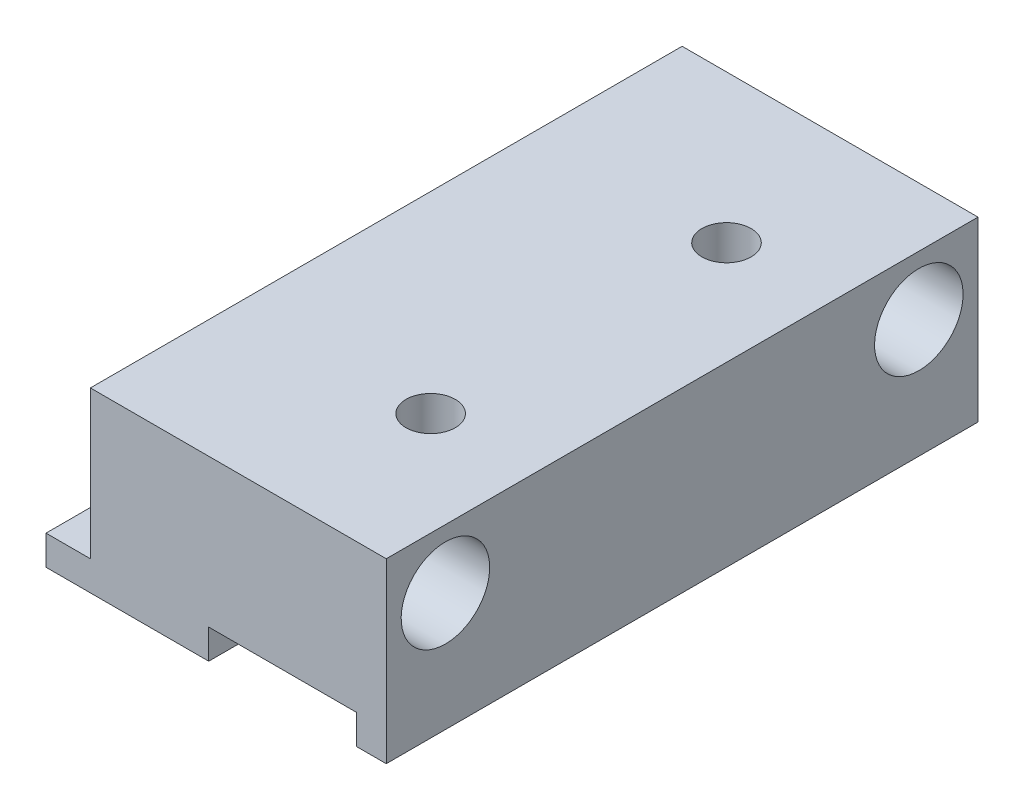
from build123d import *

# Parameters (mm, degrees)
BOSS_EXTRUDE1_DEPTH = 40
SKETCH2_R           = 2.991229743
CUT_EXTRUDE1_DEPTH  = 21
SKETCH3_R           = 1.664454023
CUT_EXTRUDE2_DEPTH  = 40


with BuildPart() as part:
    # Sketch1 → Boss-Extrude1 (new body)
    with BuildSketch(Plane.XY):
        Polygon((12.727272727, -8.568181818), (14.727272727, -8.568181818), (14.727272727, 3.431818182), (-5.272727273, 3.431818182), (-5.272727273, -6.568181818), (-8.272727273, -6.568181818), (-8.272727273, -8.568181818), (2.727272727, -8.568181818), (2.727272727, -6.568181818), (12.727272727, -6.568181818), align=None)
    extrude(amount=BOSS_EXTRUDE1_DEPTH)

    # Sketch2 → Cut-Extrude1 (cut, through all)
    with BuildSketch(Plane.ZY.offset(5.272727273)):
        with Locations((4, -0.568181818)):
            Circle(SKETCH2_R)
        with Locations((36, -0.568181818)):
            Circle(SKETCH2_R)
    extrude(amount=-CUT_EXTRUDE1_DEPTH, mode=Mode.SUBTRACT)

    # Sketch3 → Cut-Extrude2 (cut)
    with BuildSketch(Plane(origin=(0, 3.431818182, 0), x_dir=(1, 0, 0), z_dir=(0, 1, 0))):
        with Locations((7.727272727, -30)):
            Circle(SKETCH3_R)
        with Locations((7.727272727, -10)):
            Circle(SKETCH3_R)
    extrude(amount=-CUT_EXTRUDE2_DEPTH, mode=Mode.SUBTRACT)


solid = part.part
